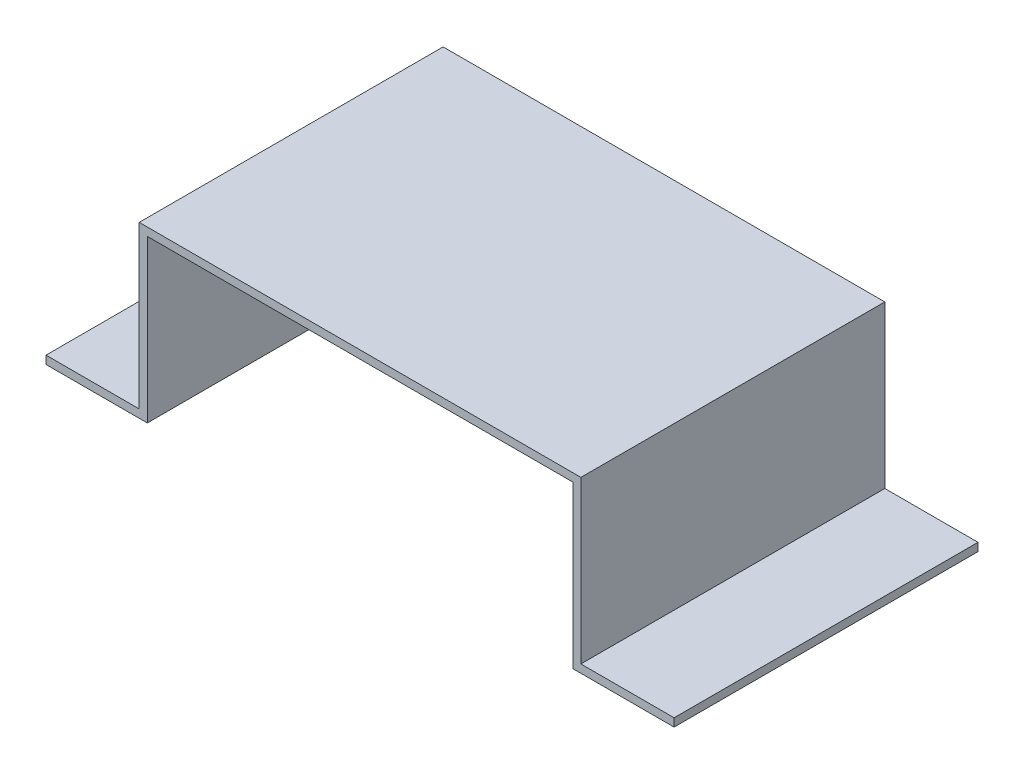
from build123d import *

# Parameters (mm, degrees)
BOSS_EXTRUDE1_DEPTH = 75


with BuildPart() as part:
    # Sketch1 → Boss-Extrude1 (new body)
    with BuildSketch(Plane.XY):
        Polygon((0, 0), (25, 0), (25, 39.878), (130, 39.878), (130, 0), (155, 0), (155, 2), (132, 2), (132, 41.878), (23, 41.878), (23, 2), (0, 2), align=None)
    extrude(amount=BOSS_EXTRUDE1_DEPTH)


solid = part.part
